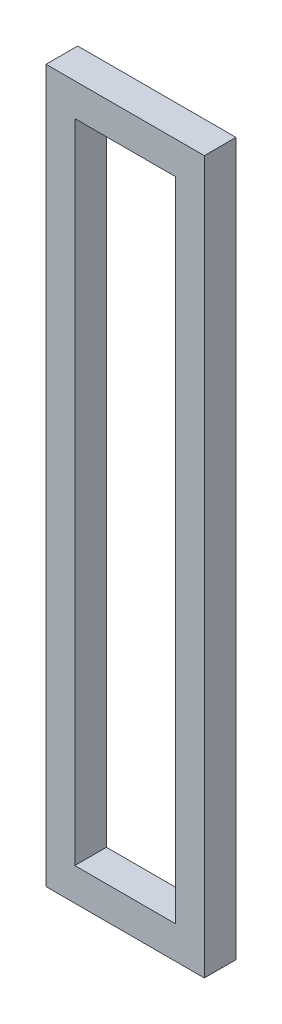
from build123d import *

# Parameters (mm, degrees)
SKETCH1_W           = 100
SKETCH1_H           = 450
BOSS_EXTRUDE1_DEPTH = 20
SKETCH2_W           = 63.712026202
SKETCH2_H           = 408.81832723
CUT_EXTRUDE1_DEPTH  = 68


with BuildPart() as part:
    # Sketch1 → Boss-Extrude1 (new body)
    with BuildSketch(Plane.XY):
        Rectangle(SKETCH1_W, SKETCH1_H)
    extrude(amount=BOSS_EXTRUDE1_DEPTH)

    # Sketch2 → Cut-Extrude1 (cut)
    with BuildSketch(Plane.XY.offset(20)):
        Rectangle(SKETCH2_W, SKETCH2_H)
    extrude(amount=-CUT_EXTRUDE1_DEPTH, mode=Mode.SUBTRACT)


solid = part.part
